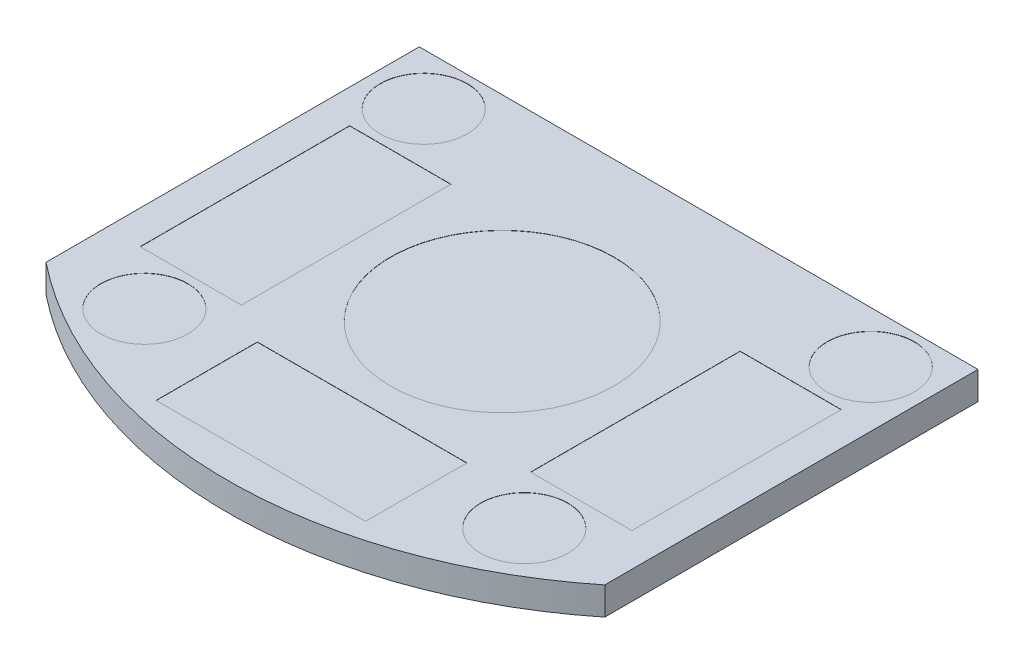
from build123d import *

# Parameters (mm, degrees)
BOSS_EXTRUDE1_DEPTH  = 12.7
BOSS_EXTRUDE2_DEPTH  = 11.176
BOSS_EXTRUDE10_DEPTH = 3.175
SKETCH22_W           = 92.185700808
SKETCH22_H           = 89.424577416
CUT_EXTRUDE13_DEPTH  = 26.4
SKETCH26_W           = 63.5
SKETCH26_H           = 12.7
BOSS_EXTRUDE11_DEPTH = 3.175
SKETCH23_R           = 4.953
SKETCH23_R_2         = 12.7
CUT_EXTRUDE14_DEPTH  = 0.0254
SKETCH25_W           = 11.509375
SKETCH25_H           = 23.8125
SKETCH25_W_2         = 23.8125
SKETCH25_H_2         = 11.509375
CUT_EXTRUDE15_DEPTH  = 0.0254
SKETCH27_W           = 63.5
SKETCH27_H           = 12.7
CUT_EXTRUDE16_DEPTH  = 4.175


with BuildPart() as part:
    # Sketch1 → Boss-Extrude1 (new body)
    with BuildSketch(Plane(origin=(0, 0, 0), x_dir=(1, 0, 0), z_dir=(0, 1, 0))):
        with BuildLine():
            Line((-31.75, 0), (31.75, 0))
            Line((31.75, 0), (31.75, -42.418))
            ThreePointArc((31.75, -42.418), (0, -53.56226271), (-31.75, -42.418))
            Line((-31.75, -42.418), (-31.75, 0))
        make_face()
    extrude(amount=BOSS_EXTRUDE1_DEPTH)

    # Sketch2 → Boss-Extrude2 (add)
    with BuildSketch(Plane.ZY.offset(19.558)):
        with BuildLine():
            Line((0, 0), (-12.7, 0))
            ThreePointArc((-12.7, 0), (-21.680256121, 21.680256121), (0, 12.7))
            Line((0, 12.7), (0, 0))
        make_face()
    boss_extrude2 = extrude(amount=-BOSS_EXTRUDE2_DEPTH)

    # Mirror1: Boss-Extrude2 across plane
    add(boss_extrude2.mirror(Plane(origin=(0, 0, 0), x_dir=(0, 0, 1), z_dir=(1, 0, 0))))

    # Sketch20 → Boss-Extrude10 (add)
    with BuildSketch(Plane.XZ):
        with BuildLine():
            Line((-31.75, 42.418), (-31.75, 0))
            Line((-31.75, 0), (-19.558, 0))
            Line((-19.558, 0), (-19.558, -12.7))
            Line((-19.558, -12.7), (-8.382, -12.7))
            Line((-8.382, -12.7), (-8.382, 0))
            Line((-8.382, 0), (8.382, 0))
            Line((8.382, 0), (8.382, -12.7))
            Line((8.382, -12.7), (19.558, -12.7))
            Line((19.558, -12.7), (19.558, 0))
            Line((19.558, 0), (31.75, 0))
            Line((31.75, 0), (31.75, 42.418))
            ThreePointArc((31.75, 42.418), (0, 53.56226271), (-31.75, 42.418))
        make_face()
    extrude(amount=BOSS_EXTRUDE10_DEPTH)

    # Sketch22 → Cut-Extrude13 (cut, through all)
    with BuildSketch(Plane(origin=(0, 0, 0), x_dir=(-1, 0, 0), z_dir=(0, -1, 0))):
        with Locations((-2.135876507, -13.211147217)):
            Rectangle(SKETCH22_W, SKETCH22_H)
    extrude(amount=-CUT_EXTRUDE13_DEPTH, mode=Mode.SUBTRACT)

    # Sketch26 → Boss-Extrude11 (add)
    with BuildSketch(Plane(origin=(0, 0, 0), x_dir=(1, 0, 0), z_dir=(0, 1, 0))):
        with Locations((0, 6.35)):
            Rectangle(SKETCH26_W, SKETCH26_H)
    extrude(amount=-BOSS_EXTRUDE11_DEPTH)

    # Sketch23 → Cut-Extrude14 (cut)
    with BuildSketch(Plane(origin=(0, 0, 0), x_dir=(1, 0, 0), z_dir=(0, 1, 0))):
        with Locations((25.4, -5.842)):
            Circle(SKETCH23_R)
        with Locations((21.59, -41.402)):
            Circle(SKETCH23_R)
        with Locations((-25.4, -5.842)):
            Circle(SKETCH23_R)
        with Locations((-21.59, -41.402)):
            Circle(SKETCH23_R)
        with Locations((0, -22.32026271)):
            Circle(SKETCH23_R_2)
    extrude(amount=-CUT_EXTRUDE14_DEPTH, mode=Mode.SUBTRACT)

    # Sketch25 → Cut-Extrude15 (cut)
    with BuildSketch(Plane(origin=(0, 0, 0), x_dir=(1, 0, 0), z_dir=(0, 1, 0))):
        with Locations((-22.1853125, -23.62201271)):
            Rectangle(SKETCH25_W, SKETCH25_H)
        with Locations((0, -43.99757521)):
            Rectangle(SKETCH25_W_2, SKETCH25_H_2)
        with Locations((22.1853125, -23.62201271)):
            Rectangle(SKETCH25_W, SKETCH25_H)
    extrude(amount=-CUT_EXTRUDE15_DEPTH, mode=Mode.SUBTRACT)

    # Sketch27 → Cut-Extrude16 (cut, through all)
    with BuildSketch(Plane(origin=(0, 0, 0), x_dir=(1, 0, 0), z_dir=(0, 1, 0))):
        with Locations((0, 6.35)):
            Rectangle(SKETCH27_W, SKETCH27_H)
    extrude(amount=-CUT_EXTRUDE16_DEPTH, mode=Mode.SUBTRACT)


solid = part.part
